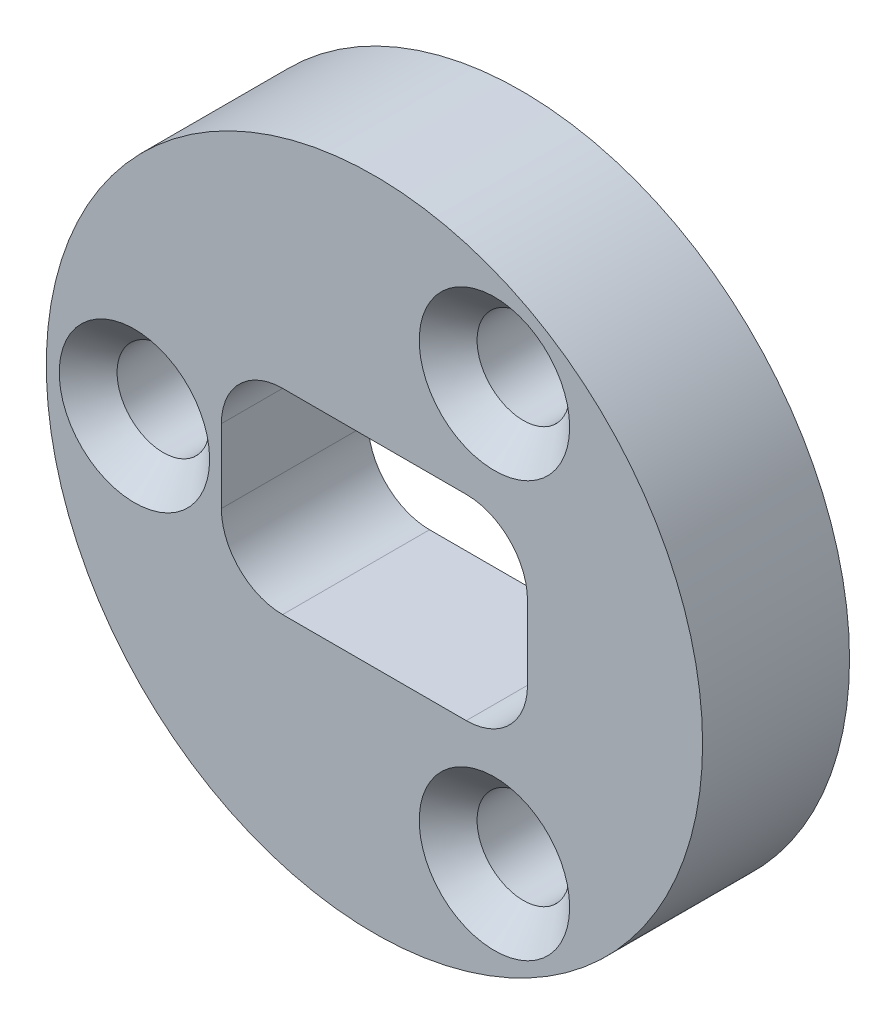
from build123d import *

# Parameters (mm, degrees)
SKETCH1_R            = 8.509
BOSS_EXTRUDE1_DEPTH  = 3.81
SKETCH3_W            = 7.9375
SKETCH3_H            = 5.08
CUT_EXTRUDE2_DEPTH   = 3.81
M2_CLEARANCE_HOLE1_D = 2.4
FILLET1_R            = 1.5875
CHAMFER1_SIZE        = 0.75


with BuildPart() as part:
    # Sketch1 → Boss-Extrude1 (new body)
    with BuildSketch(Plane.XY):
        Circle(SKETCH1_R)
    extrude(amount=BOSS_EXTRUDE1_DEPTH)

    # Sketch3 → Cut-Extrude2 (cut)
    with BuildSketch(Plane.XY.offset(3.81)):
        Rectangle(SKETCH3_W, SKETCH3_H)
    extrude(amount=-CUT_EXTRUDE2_DEPTH, mode=Mode.SUBTRACT)

    # M2 Clearance Hole1 (through all)
    with Locations(Plane.XY.offset(3.81)):
        with Locations((-6.223, 0), (3.1115, 5.389276088), (3.1115, -5.389276088)):
            Hole(M2_CLEARANCE_HOLE1_D / 2)

    # Fillet1
    fillet1_edges = [part.edges().sort_by_distance(p)[0] for p in [
        (3.96875, 2.54, 1.905),
        (3.96875, -2.54, 1.905),
        (-3.96875, -2.54, 1.905),
        (-3.96875, 2.54, 1.905),
    ]]
    fillet(fillet1_edges, radius=FILLET1_R)

    # Chamfer1
    chamfer1_edges = [part.edges().sort_by_distance(p)[0] for p in [
        (4.3115, -5.389276088, 3.81),
        (4.3115, 5.389276088, 3.81),
        (-5.023, 0, 3.81),
    ]]
    chamfer(chamfer1_edges, length=CHAMFER1_SIZE)


solid = part.part
